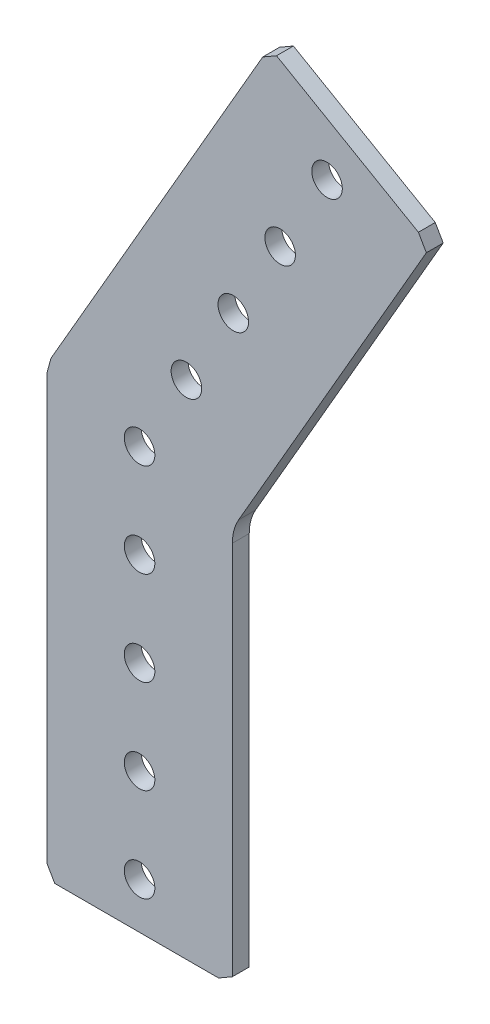
from build123d import *

# Parameters (mm, degrees)
SKETCH1_R           = 2.0701
BOSS_EXTRUDE1_DEPTH = 2.286


with BuildPart() as part:
    # Sketch1 → Boss-Extrude1 (new body)
    with BuildSketch(Plane.XY.offset(2.286)):
        with BuildLine():
            Line((16.688088175, 54.0506166), (-12.014209682, 4.336778419))
            Line((-12.014209682, 4.336778419), (-12.573, 2.25134456))
            Line((-12.573, 2.25134456), (-12.573, -55.153251153))
            Line((-12.573, -55.153251153), (-11.4935, -57.023))
            Line((-11.4935, -57.023), (10.703251153, -57.023))
            Line((10.703251153, -57.023), (12.573, -55.9435))
            Line((12.573, -55.9435), (12.573, -5.070402568))
            ThreePointArc((12.573, -5.070402568), (12.789371003, -3.426901632), (13.423738686, -1.895402568))
            Line((13.423738686, -1.895402568), (38.860287402, 42.161992177))
            Line((38.860287402, 42.161992177), (37.780787402, 44.031741023))
            Line((37.780787402, 44.031741023), (18.557837022, 55.1301166))
            Line((18.557837022, 55.1301166), (16.688088175, 54.0506166))
        make_face()
        Circle(SKETCH1_R, mode=Mode.SUBTRACT)
        with Locations((0, -38.1)):
            Circle(SKETCH1_R, mode=Mode.SUBTRACT)
        with Locations((0, -12.7)):
            Circle(SKETCH1_R, mode=Mode.SUBTRACT)
        with Locations((0, -25.4)):
            Circle(SKETCH1_R, mode=Mode.SUBTRACT)
        with Locations((0, -50.8)):
            Circle(SKETCH1_R, mode=Mode.SUBTRACT)
        with Locations((19.05, 32.995567884)):
            Circle(SKETCH1_R, mode=Mode.SUBTRACT)
        with Locations((6.35, 10.998522628)):
            Circle(SKETCH1_R, mode=Mode.SUBTRACT)
        with Locations((12.7, 21.997045256)):
            Circle(SKETCH1_R, mode=Mode.SUBTRACT)
        with Locations((25.4, 43.994090512)):
            Circle(SKETCH1_R, mode=Mode.SUBTRACT)
    extrude(amount=-BOSS_EXTRUDE1_DEPTH)


solid = part.part
